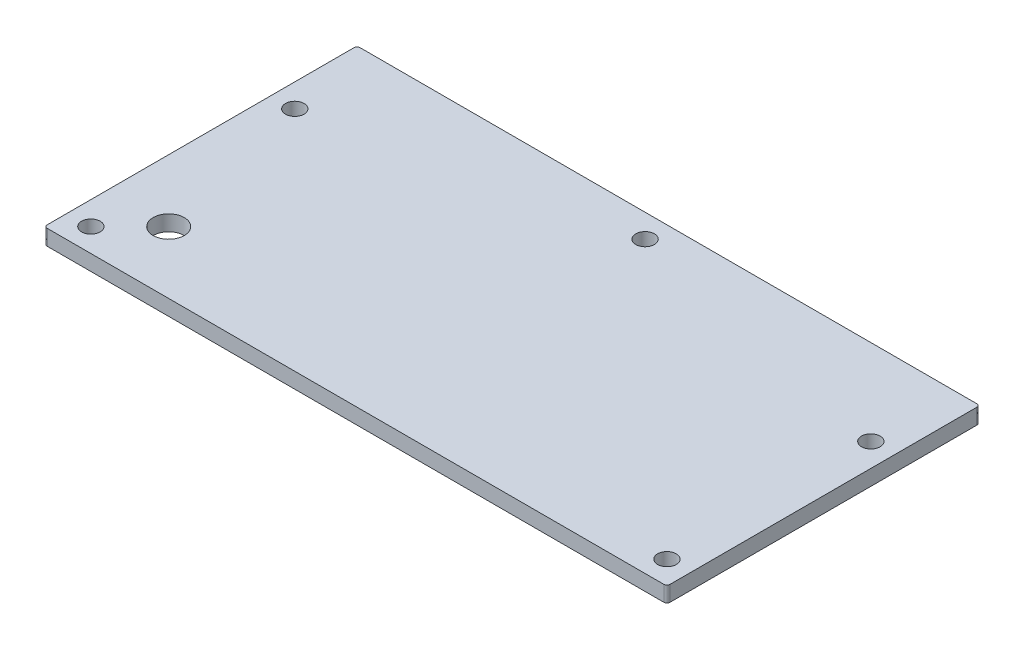
from build123d import *

# Parameters (mm, degrees)
SKETCH1_W           = 127
SKETCH1_H           = 63.8048
BOSS_EXTRUDE1_DEPTH = 3.175
SKETCH4_R           = 1.89865
CUT_EXTRUDE3_DEPTH  = 4.175
SKETCH5_R           = 3.175
CUT_EXTRUDE4_DEPTH  = 4.175
FILLET2_R           = 0.635


with BuildPart() as part:
    # Sketch1 → Boss-Extrude1 (new body)
    with BuildSketch(Plane(origin=(0, 0, 0), x_dir=(1, 0, 0), z_dir=(0, 1, 0))):
        Rectangle(SKETCH1_W, SKETCH1_H)
    extrude(amount=BOSS_EXTRUDE1_DEPTH)

    # Sketch4 → Cut-Extrude3 (cut, through all)
    with BuildSketch(Plane(origin=(0, 3.175, 0), x_dir=(1, 0, 0), z_dir=(0, 1, 0))):
        with Locations((-58.7375, -27.1399)):
            Circle(SKETCH4_R)
        with Locations((-58.7375, 14.4399)):
            Circle(SKETCH4_R)
        with Locations((58.7375, 14.4399)):
            Circle(SKETCH4_R)
        with Locations((58.7375, -27.1399)):
            Circle(SKETCH4_R)
        with Locations((0, 27.1399)):
            Circle(SKETCH4_R)
    extrude(amount=-CUT_EXTRUDE3_DEPTH, mode=Mode.SUBTRACT)

    # Sketch5 → Cut-Extrude4 (cut, through all)
    with BuildSketch(Plane(origin=(0, 3.175, 0), x_dir=(1, 0, 0), z_dir=(0, 1, 0))):
        with Locations((-50.8, -19.2024)):
            Circle(SKETCH5_R)
    extrude(amount=-CUT_EXTRUDE4_DEPTH, mode=Mode.SUBTRACT)

    # Fillet2
    fillet2_edges = [part.edges().sort_by_distance(p)[0] for p in [
        (63.5, 1.5875, 31.9024),
        (-63.5, 1.5875, 31.9024),
        (-63.5, 1.5875, -31.9024),
        (63.5, 1.5875, -31.9024),
    ]]
    fillet(fillet2_edges, radius=FILLET2_R)


solid = part.part
